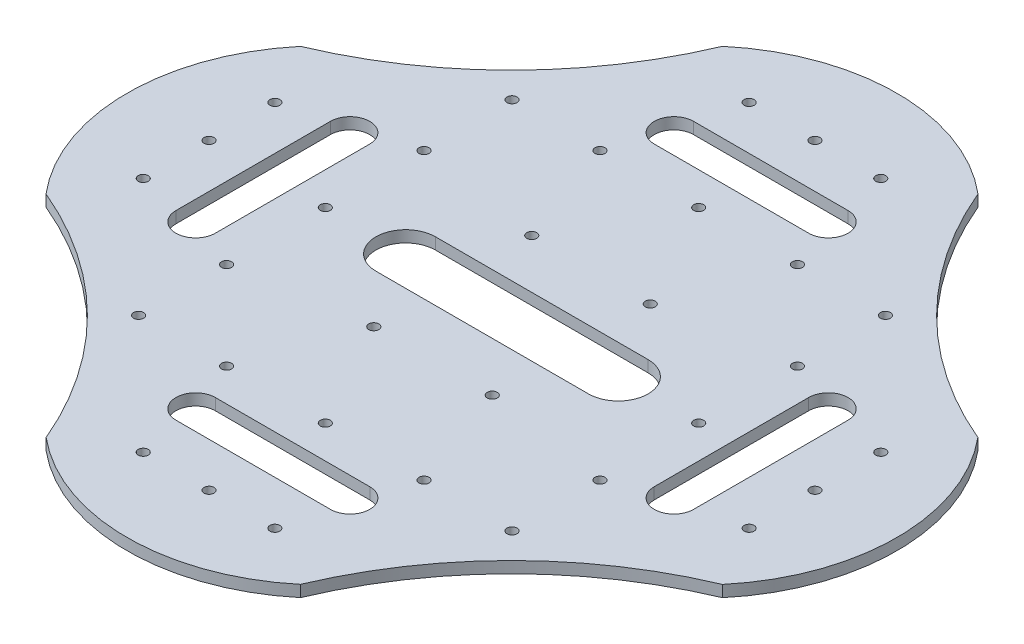
from build123d import *

# Parameters (mm, degrees)
SKETCH_2_R          = 1.520000009
SKETCH_2_R_2        = 1.519999991
SKETCH_2_R_3        = 1.520000003
SKETCH_2_R_4        = 1.519999997
EXTRUDE_3_DEPTH     = 3.5
SKETCH_4_R          = 1.52
CUT_EXTRUDE_2_DEPTH = 59


with BuildPart() as part:
    # 草图2 → 凸台-拉伸3 (new body)
    with BuildSketch(Plane(origin=(0, 0, 0), x_dir=(1, 0, 0), z_dir=(0, 1, 0))):
        with BuildLine():
            ThreePointArc((-11.441254589, -132.131794893), (14.330726674, -93.804971939), (52.669453823, -68.050702844))
            ThreePointArc((52.669453823, -68.050702844), (66.860009927, -29.340594642), (52.82507606, 9.426208049))
            ThreePointArc((52.82507606, 9.426208049), (14.498253105, 35.198189312), (-11.25601599, 73.536916461))
            ThreePointArc((-11.25601599, 73.536916461), (-50.087090736, 87.727594053), (-88.918165482, 73.536916461))
            ThreePointArc((-88.918165482, 73.536916461), (-114.672434576, 35.198189312), (-152.999257531, 9.426208049))
            ThreePointArc((-152.999257531, 9.426208049), (-167.034191399, -29.340594642), (-152.843635295, -68.050702844))
            ThreePointArc((-152.843635295, -68.050702844), (-114.504908145, -93.804971939), (-88.732926883, -132.131794893))
            ThreePointArc((-88.732926883, -132.131794893), (-50.087090736, -146.166850249), (-11.441254589, -132.131794893))
        make_face()
        with Locations((-106.810701812, -85.943239174)):
            Circle(SKETCH_2_R, mode=Mode.SUBTRACT)
        with Locations((-70.087090736, -121.269794335)):
            Circle(SKETCH_2_R, mode=Mode.SUBTRACT)
        with Locations((-80.087090736, -85.943239174)):
            Circle(SKETCH_2_R, mode=Mode.SUBTRACT)
        with Locations((-106.810701812, -59.219628098)):
            Circle(SKETCH_2_R, mode=Mode.SUBTRACT)
        with Locations((-142.137256973, -49.219628098)):
            Circle(SKETCH_2_R, mode=Mode.SUBTRACT)
        with Locations((-50.087090736, -121.269794335)):
            Circle(SKETCH_2_R, mode=Mode.SUBTRACT)
        with Locations((-30.087090736, -121.269794335)):
            Circle(SKETCH_2_R, mode=Mode.SUBTRACT)
        with BuildLine():
            Line((-73.555048946, -95.906459136), (-26.619132526, -95.906459136))
            ThreePointArc((-26.619132526, -95.906459136), (-20.644330739, -101.881260923), (-26.619132526, -107.856062709))
            Line((-26.619132526, -107.856062709), (-73.555048946, -107.856062709))
            ThreePointArc((-73.555048946, -107.856062709), (-79.529850733, -101.881260923), (-73.555048946, -95.906459136))
        make_face(mode=Mode.SUBTRACT)
        with Locations((-50.087090736, -85.943239174)):
            Circle(SKETCH_2_R_2, mode=Mode.SUBTRACT)
        with Locations((-20.087090736, -85.943239174)):
            Circle(SKETCH_2_R, mode=Mode.SUBTRACT)
        with BuildLine():
            Line((10.039848898, -89.354171782), (10.033073964, -89.34738171))
            ThreePointArc((10.033073964, -89.34738171), (10.036665339, -89.34717873), (10.040256701, -89.346975535))
            ThreePointArc((10.040256701, -89.346975535), (10.040052907, -89.350573664), (10.039848898, -89.354171782))
        make_face(mode=Mode.SUBTRACT)
        with Locations((6.63652034, -85.943239174)):
            Circle(SKETCH_2_R, mode=Mode.SUBTRACT)
        with BuildLine():
            ThreePointArc((-82.385679365, -38.265938506), (-91.431989773, -29.219628098), (-82.385679365, -20.17331769))
            Line((-82.385679365, -20.17331769), (-17.788502107, -20.17331769))
            ThreePointArc((-17.788502107, -20.17331769), (-8.742191699, -29.219628098), (-17.788502107, -38.265938506))
            Line((-17.788502107, -38.265938506), (-82.385679365, -38.265938506))
        make_face(mode=Mode.SUBTRACT)
        with Locations((6.63652034, -59.219628098)):
            Circle(SKETCH_2_R_3, mode=Mode.SUBTRACT)
        with Locations((41.963075501, -49.219628098)):
            Circle(SKETCH_2_R_3, mode=Mode.SUBTRACT)
        with Locations((-142.137256973, -29.219628098)):
            Circle(SKETCH_2_R, mode=Mode.SUBTRACT)
        with BuildLine():
            Line((-128.723525347, -52.687586308), (-128.723525347, -5.751669888))
            ThreePointArc((-128.723525347, -5.751669888), (-122.74872356, 0.223131899), (-116.773921774, -5.751669888))
            Line((-116.773921774, -5.751669888), (-116.773921774, -52.687586308))
            ThreePointArc((-116.773921774, -52.687586308), (-122.74872356, -58.662388095), (-128.723525347, -52.687586308))
        make_face(mode=Mode.SUBTRACT)
        with Locations((-142.137256973, -9.219628098)):
            Circle(SKETCH_2_R, mode=Mode.SUBTRACT)
        with Locations((-106.810701812, -29.219628098)):
            Circle(SKETCH_2_R_4, mode=Mode.SUBTRACT)
        with Locations((-106.810701812, 0.780371902)):
            Circle(SKETCH_2_R, mode=Mode.SUBTRACT)
        with Locations((-106.810701812, 27.503982978)):
            Circle(SKETCH_2_R, mode=Mode.SUBTRACT)
        with Locations((-80.087090736, 27.503982978)):
            Circle(SKETCH_2_R, mode=Mode.SUBTRACT)
        with Locations((-70.087090736, 62.830538139)):
            Circle(SKETCH_2_R, mode=Mode.SUBTRACT)
        with Locations((6.63652034, -29.219628098)):
            Circle(SKETCH_2_R_3, mode=Mode.SUBTRACT)
        with BuildLine():
            ThreePointArc((16.599740302, -5.751669888), (22.574542089, 0.223131899), (28.549343876, -5.751669888))
            Line((28.549343876, -5.751669888), (28.549343876, -52.687586308))
            ThreePointArc((28.549343876, -52.687586308), (22.574542089, -58.662388095), (16.599740302, -52.687586308))
            Line((16.599740302, -52.687586308), (16.599740302, -5.751669888))
        make_face(mode=Mode.SUBTRACT)
        with Locations((41.963075501, -29.219628098)):
            Circle(SKETCH_2_R_3, mode=Mode.SUBTRACT)
        with Locations((41.963075501, -9.219628098)):
            Circle(SKETCH_2_R_3, mode=Mode.SUBTRACT)
        with Locations((6.63652034, 0.780371902)):
            Circle(SKETCH_2_R_3, mode=Mode.SUBTRACT)
        with Locations((-50.087090736, 27.503982978)):
            Circle(SKETCH_2_R_4, mode=Mode.SUBTRACT)
        with Locations((-20.087090736, 27.503982978)):
            Circle(SKETCH_2_R, mode=Mode.SUBTRACT)
        with BuildLine():
            Line((-73.555048946, 49.416806513), (-26.619132526, 49.416806513))
            ThreePointArc((-26.619132526, 49.416806513), (-20.644330739, 43.442004727), (-26.619132526, 37.46720294))
            Line((-26.619132526, 37.46720294), (-73.555048946, 37.46720294))
            ThreePointArc((-73.555048946, 37.46720294), (-79.529850733, 43.442004727), (-73.555048946, 49.416806513))
        make_face(mode=Mode.SUBTRACT)
        with Locations((-50.087090736, 62.830538139)):
            Circle(SKETCH_2_R, mode=Mode.SUBTRACT)
        with Locations((-30.087090736, 62.830538139)):
            Circle(SKETCH_2_R, mode=Mode.SUBTRACT)
        with Locations((6.63652034, 27.503982978)):
            Circle(SKETCH_2_R, mode=Mode.SUBTRACT)
    extrude(amount=EXTRUDE_3_DEPTH)

    # 草图4 → 切除-拉伸2 (cut)
    with BuildSketch(Plane.XZ.offset(-7.25)):
        with Locations((-68.087090727, 5.219628098)):
            Circle(SKETCH_4_R)
        with Locations((-32.087090727, 5.219628098)):
            Circle(SKETCH_4_R)
        with Locations((-68.087090727, 53.219628098)):
            Circle(SKETCH_4_R)
        with Locations((-32.087090727, 53.219628098)):
            Circle(SKETCH_4_R)
    extrude(amount=CUT_EXTRUDE_2_DEPTH, mode=Mode.SUBTRACT)


solid = part.part
